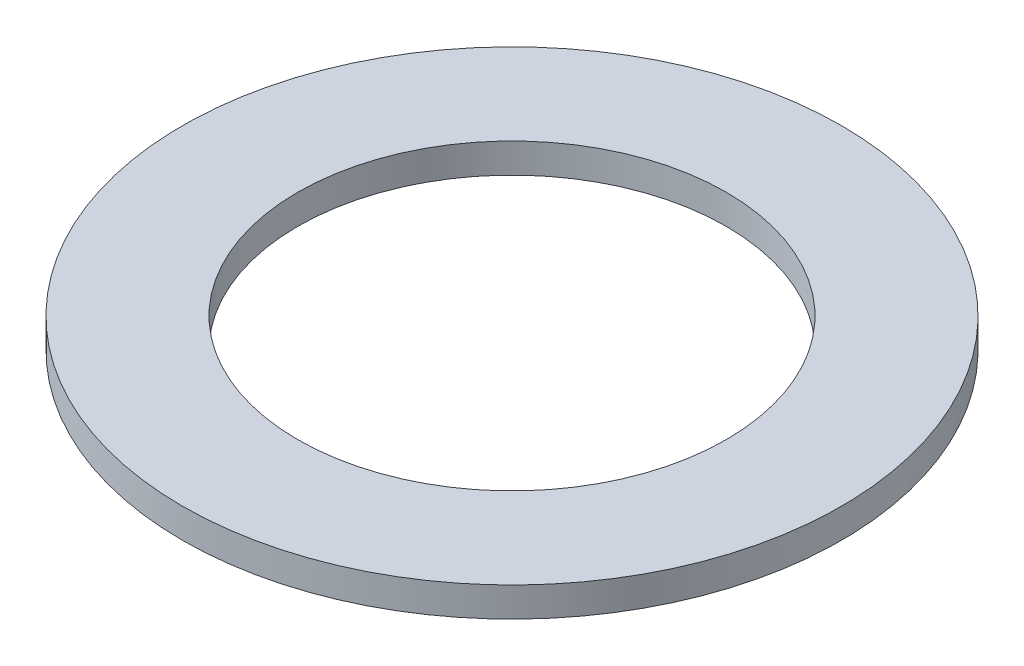
from build123d import *

# Parameters (mm, degrees)
SKETCH1_R           = 22.0726
SKETCH1_R_2         = 14.351
BOSS_EXTRUDE1_DEPTH = 1.9812


with BuildPart() as part:
    # Sketch1 → Boss-Extrude1 (new body)
    with BuildSketch(Plane(origin=(0, 0, 0), x_dir=(1, 0, 0), z_dir=(0, 1, 0))):
        Circle(SKETCH1_R)
        Circle(SKETCH1_R_2, mode=Mode.SUBTRACT)
    extrude(amount=BOSS_EXTRUDE1_DEPTH)


solid = part.part
